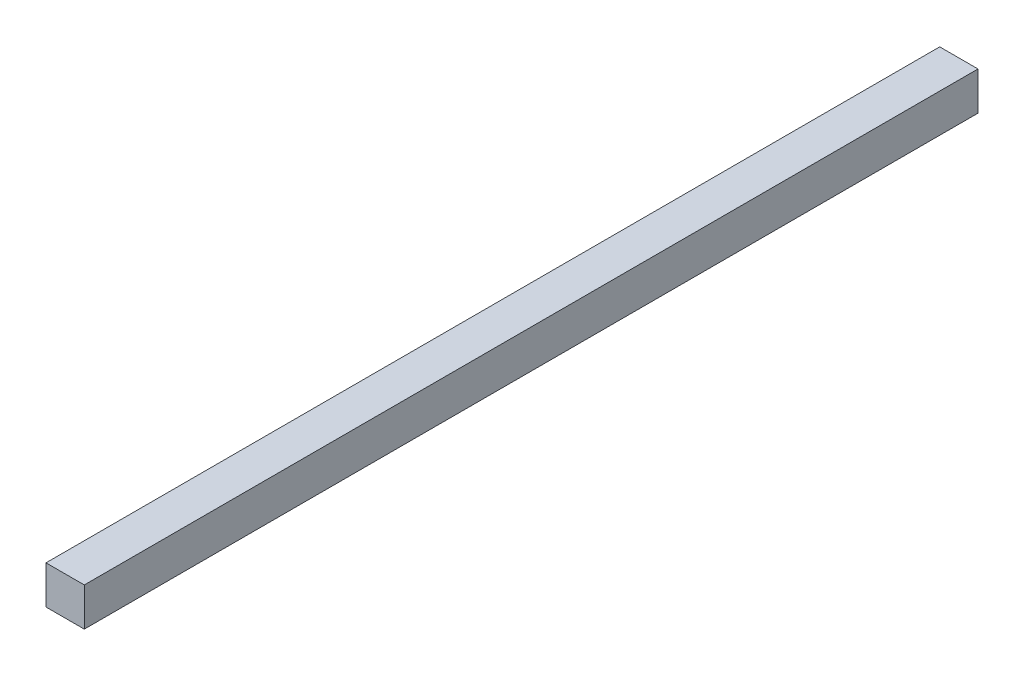
from build123d import *

# Parameters (mm, degrees)
SKETCH_1_W      = 30
SKETCH_1_H      = 30
EXTRUDE_1_DEPTH = 700


with BuildPart() as part:
    # 스케치1 → 보스-돌출1 (new body)
    with BuildSketch(Plane.XY):
        Rectangle(SKETCH_1_W, SKETCH_1_H)
    extrude(amount=EXTRUDE_1_DEPTH)


solid = part.part
